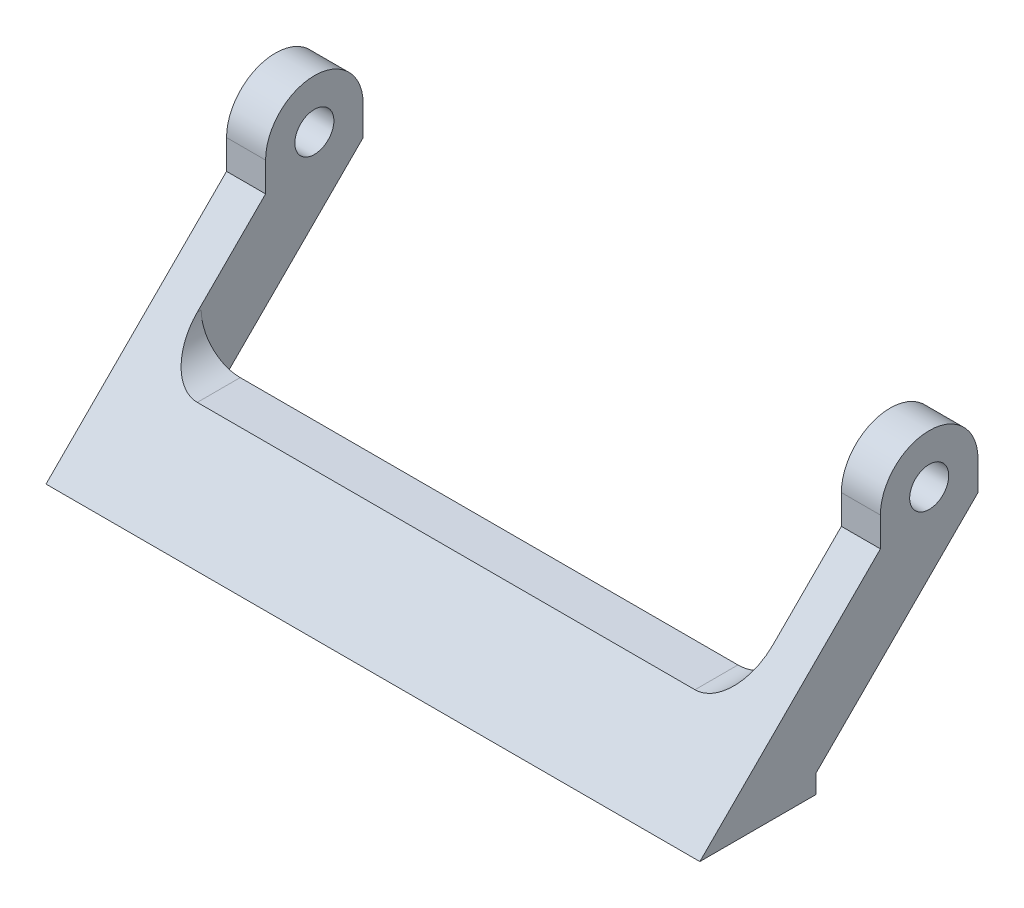
from build123d import *

# Parameters (mm, degrees)
SKETCH1_R           = 2
BOSS_EXTRUDE1_DEPTH = 67
CUT_EXTRUDE1_REACH  = 30.5
CUT_EXTRUDE2_REACH  = 28.5
SKETCH3_W           = 59
SKETCH3_H           = 9.6


with BuildPart() as part:
    # Sketch1 → Boss-Extrude1 (new body)
    with BuildSketch(Plane(origin=(0, 0, 0), x_dir=(0, 0, -1), z_dir=(1, 0, 0))):
        with BuildLine():
            Line((11.9, 1.9), (11.9, 0))
            Line((11.9, 0), (0, 0))
            Line((0, 0), (18.5, 18.5))
            Line((18.5, 18.5), (18.5, 21.5))
            ThreePointArc((18.5, 21.5), (23.5, 26.5), (28.5, 21.5))
            Line((28.5, 21.5), (28.5, 18.5))
            Line((28.5, 18.5), (11.9, 1.9))
        make_face()
        with Locations((23.5, 21.5)):
            Circle(SKETCH1_R, mode=Mode.SUBTRACT)
    extrude(amount=BOSS_EXTRUDE1_DEPTH)

    # Sketch2 → Cut-Extrude1 (cut, up to next)
    with BuildSketch(Plane(origin=(0, 0, -28.5), x_dir=(-1, 0, 0), z_dir=(0, 0, -1)), mode=Mode.PRIVATE) as cut_extrude1_sk1:
        with BuildLine():
            Line((-63, 26.5), (-63, 11.5))
            ThreePointArc((-63, 11.5), (-61.828427125, 8.671572875), (-59, 7.5))
            Line((-59, 7.5), (-8, 7.5))
            ThreePointArc((-8, 7.5), (-5.171572875, 8.671572875), (-4, 11.5))
            Line((-4, 11.5), (-4, 26.5))
            Line((-4, 26.5), (-63, 26.5))
        make_face()
    cut_extrude1_tool1 = extrude(cut_extrude1_sk1.sketch, amount=-CUT_EXTRUDE1_REACH, mode=Mode.PRIVATE) & part.part
    add(cut_extrude1_tool1.solids().sort_by_distance((33.5, 17.053049, -28.5))[0], mode=Mode.SUBTRACT)

    # Sketch3 → Cut-Extrude2 (cut, up to next)
    with BuildSketch(Plane.XZ, mode=Mode.PRIVATE) as cut_extrude2_sk1:
        with Locations((33.5, -16.7)):
            Rectangle(SKETCH3_W, SKETCH3_H)
    cut_extrude2_tool1 = extrude(cut_extrude2_sk1.sketch, amount=-CUT_EXTRUDE2_REACH, mode=Mode.PRIVATE) & part.part
    add(cut_extrude2_tool1.solids().sort_by_distance((33.5, 0, -16.7))[0], mode=Mode.SUBTRACT)


solid = part.part
